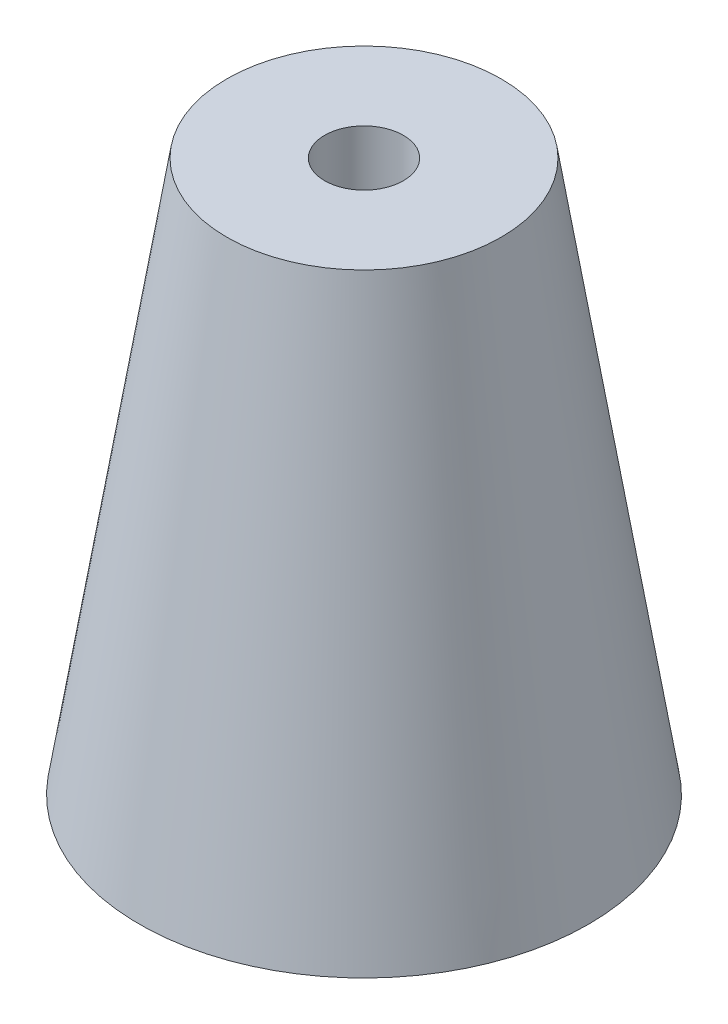
from build123d import *

# Parameters (mm, degrees)
SKETCH3_R          = 6.35
CUT_EXTRUDE1_DEPTH = 89.9
SHELL1_T           = -1.27
FILLET1_R          = 2.54


with BuildPart() as part:
    # Sketch2 → Revolve1 (revolve)
    with BuildSketch(Plane.XY):
        Polygon((0, 0), (36.195, 0), (22.119166667, 88.9), (0, 88.9), align=None)
    revolve(axis=Axis((0, 88.9, 0), (0, -1, 0)))

    # Sketch3 → Cut-Extrude1 (cut, through all)
    with BuildSketch(Plane.XZ):
        Circle(SKETCH3_R)
    extrude(amount=-CUT_EXTRUDE1_DEPTH, mode=Mode.SUBTRACT)

    # Shell1
    shell1_openings = [part.faces().sort_by_distance(p)[0] for p in [
        (6.35, 0, 0),
    ]]
    offset(amount=SHELL1_T, openings=shell1_openings, kind=Kind.INTERSECTION)

    # Fillet1
    fillet1_edges = [part.edges().sort_by_distance(p)[0] for p in [
        (-7.62, 87.63, 0),
        (-21.034429442, 87.63, 0),
    ]]
    fillet(fillet1_edges, radius=FILLET1_R)


solid = part.part
